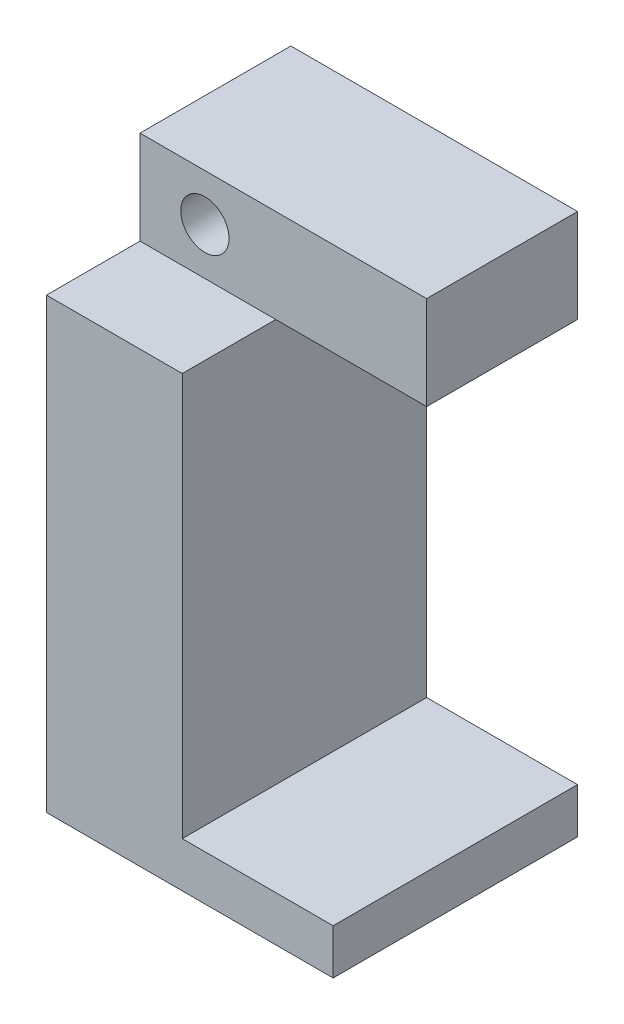
from build123d import *

# Parameters (mm, degrees)
SALIENTE_EXTRUIR1_DEPTH = 10
SALIENTE_EXTRUIR2_DEPTH = 6.2
CORTAR_EXTRUIR1_REACH   = 12
CROQUIS3_R              = 1.6
CORTAR_EXTRUIR2_DEPTH   = 3


with BuildPart() as part:
    # Croquis1 → Saliente-Extruir1 (new body)
    with BuildSketch(Plane.XY):
        Polygon((0, 0), (19, 0), (19, 3), (9, 3), (9, 29.7), (19, 29.7), (19, 35.9), (0, 35.9), align=None)
    extrude(amount=SALIENTE_EXTRUIR1_DEPTH)

    # Croquis2 → Saliente-Extruir2 (add)
    with BuildSketch(Plane.XY.offset(10)):
        Polygon((9, 29.7), (0, 29.7), (0, 0), (19, 0), (19, 3), (9, 3), align=None)
    extrude(amount=SALIENTE_EXTRUIR2_DEPTH)

    # Croquis3 → Cortar-Extruir1 (cut, up to next)
    with BuildSketch(Plane.XY.offset(10), mode=Mode.PRIVATE) as cortar_extruir1_sk1:
        with Locations((4.3, 32.8)):
            Circle(CROQUIS3_R)
    cortar_extruir1_tool1 = extrude(cortar_extruir1_sk1.sketch, amount=-CORTAR_EXTRUIR1_REACH, mode=Mode.PRIVATE) & part.part
    add(cortar_extruir1_tool1.solids().sort_by_distance((4.3, 32.8, 10))[0], mode=Mode.SUBTRACT)

    # Croquis4 → Cortar-Extruir2 (cut)
    with BuildSketch(Plane(origin=(0, 0, 0), x_dir=(-1, 0, 0), z_dir=(0, 0, -1))):
        Polygon((-2.654551733, 35.65), (-5.945448267, 35.65), (-7.590896534, 32.8), (-5.945448267, 29.95), (-2.654551733, 29.95), (-1.009103466, 32.8), align=None)
    extrude(amount=-CORTAR_EXTRUIR2_DEPTH, mode=Mode.SUBTRACT)


solid = part.part
